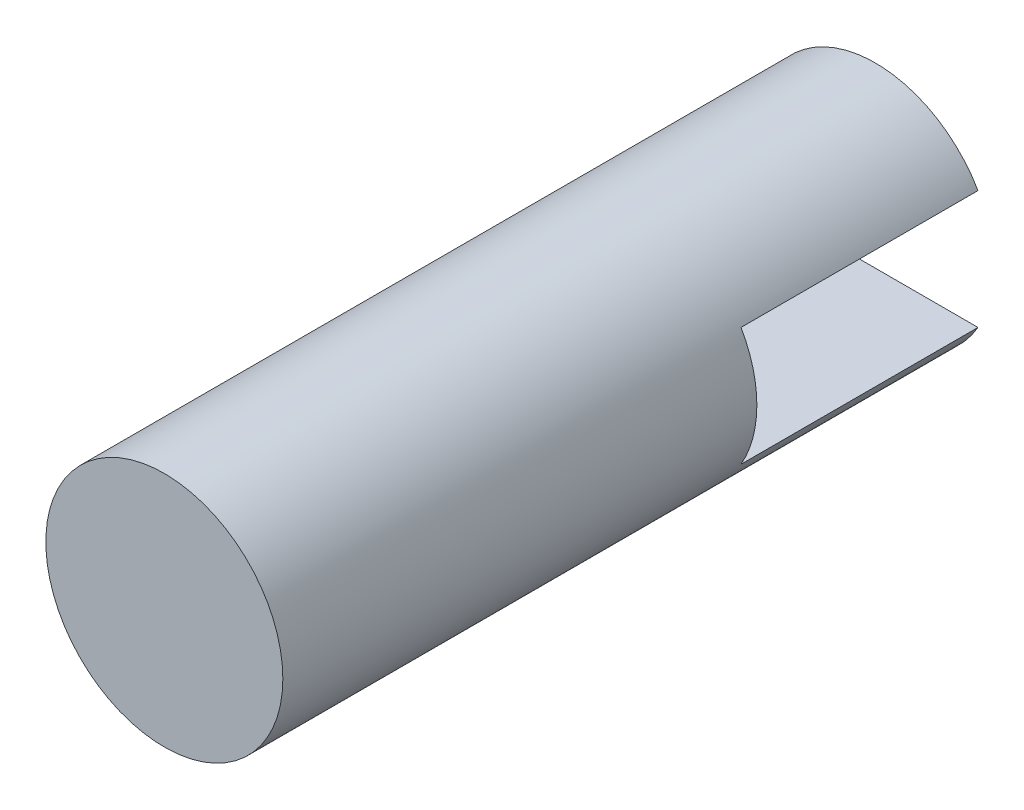
from build123d import *

# Parameters (mm, degrees)
SKETCH1_R                = 5
BOSS_EXTRUDE1_DEPTH      = 25
BOSS_EXTRUDE1_DEPTH_BACK = 5
SKETCH3_W                = 10
SKETCH3_H                = 5
CUT_EXTRUDE2_DEPTH       = 6
CUT_EXTRUDE2_DEPTH_BACK  = 6


with BuildPart() as part:
    # Sketch1 → Boss-Extrude1 (new body, two sides)
    with BuildSketch(Plane.XY) as boss_extrude1_sk:
        Circle(SKETCH1_R)
    extrude(amount=BOSS_EXTRUDE1_DEPTH)
    extrude(boss_extrude1_sk.sketch, amount=-BOSS_EXTRUDE1_DEPTH_BACK)

    # Sketch3 → Cut-Extrude2 (cut, two sides)
    with BuildSketch(Plane(origin=(0, 0, 0), x_dir=(0, 0, -1), z_dir=(1, 0, 0))) as cut_extrude2_sk:
        Rectangle(SKETCH3_W, SKETCH3_H)
    extrude(amount=CUT_EXTRUDE2_DEPTH, mode=Mode.SUBTRACT)
    extrude(cut_extrude2_sk.sketch, amount=-CUT_EXTRUDE2_DEPTH_BACK, mode=Mode.SUBTRACT)


solid = part.part
